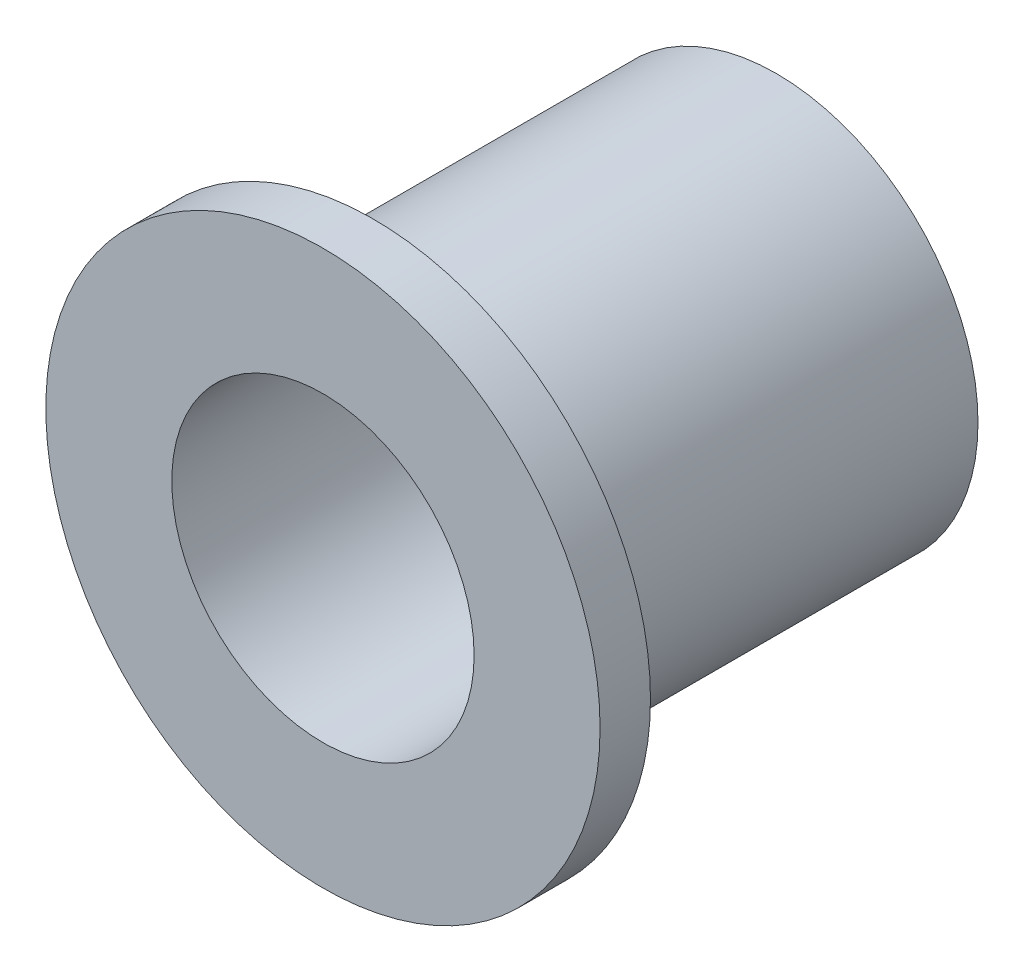
from build123d import *

# Parameters (mm, degrees)
SKETCH1_R           = 8.73125
BOSS_EXTRUDE1_DEPTH = 1.5875
SKETCH2_R           = 6.35
BOSS_EXTRUDE2_DEPTH = 12.7
SKETCH3_R           = 4.7625
CUT_EXTRUDE1_DEPTH  = 15.2875


with BuildPart() as part:
    # Sketch1 → Boss-Extrude1 (new body)
    with BuildSketch(Plane.XY):
        Circle(SKETCH1_R)
    extrude(amount=BOSS_EXTRUDE1_DEPTH)

    # Sketch2 → Boss-Extrude2 (add)
    with BuildSketch(Plane(origin=(0, 0, 0), x_dir=(-1, 0, 0), z_dir=(0, 0, -1))):
        Circle(SKETCH2_R)
    extrude(amount=BOSS_EXTRUDE2_DEPTH)

    # Sketch3 → Cut-Extrude1 (cut, through all)
    with BuildSketch(Plane.XY.offset(1.5875)):
        Circle(SKETCH3_R)
    extrude(amount=-CUT_EXTRUDE1_DEPTH, mode=Mode.SUBTRACT)


solid = part.part
